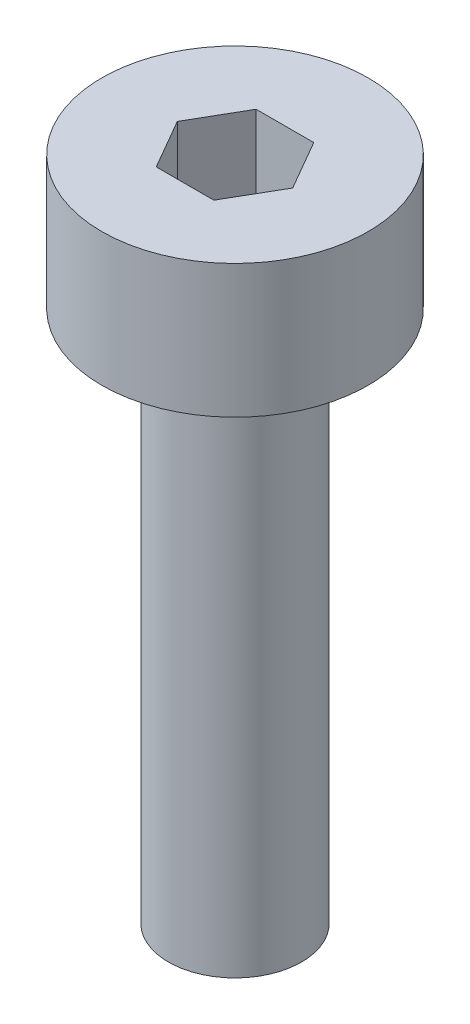
from build123d import *

# Parameters (mm, degrees)
SKETCH_1_R            = 2
EXTRUDE_246_DEPTH     = 2
CUT_EXTRUDE_376_DEPTH = 1.5
SKETCH_3_R            = 1
EXTRUDE_477_DEPTH     = 8


with BuildPart() as part:
    # 草图1 → Extrude 246 (new body)
    with BuildSketch(Plane(origin=(0, 0, 0), x_dir=(1, 0, 0), z_dir=(0, 1, 0))):
        Circle(SKETCH_1_R)
    extrude(amount=EXTRUDE_246_DEPTH)

    # 草图2 → Cut-Extrude 376 (cut)
    with BuildSketch(Plane(origin=(0, 2, 0), x_dir=(1, 0, 0), z_dir=(0, 1, 0))):
        Polygon((0.866025404, 0), (0.433012702, 0.75), (-0.433012702, 0.75), (-0.866025404, 0), (-0.433012702, -0.75), (0.433012702, -0.75), align=None)
    extrude(amount=-CUT_EXTRUDE_376_DEPTH, mode=Mode.SUBTRACT)

    # 草图3 → Extrude 477 (add)
    with BuildSketch(Plane.XZ):
        Circle(SKETCH_3_R)
    extrude(amount=EXTRUDE_477_DEPTH)


solid = part.part
